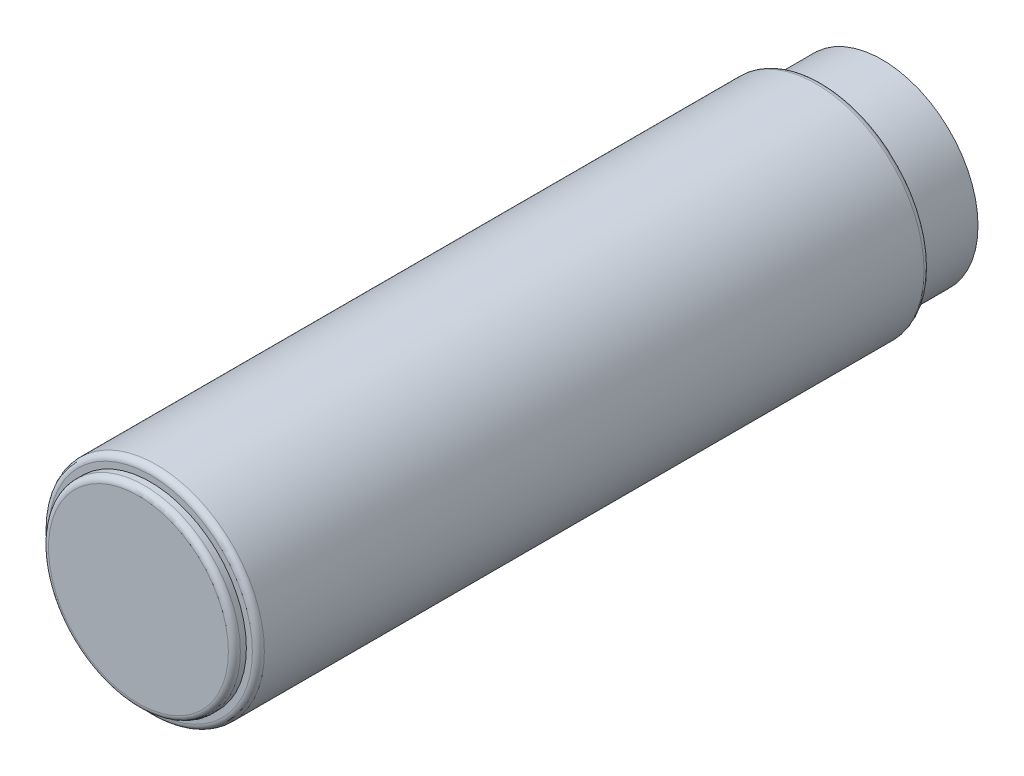
from build123d import *

# Parameters (mm, degrees)
ESQUISSE1_R        = 9
BOSS_EXTRU_1_DEPTH = 56
ESQUISSE2_R        = 8
BOSS_EXTRU_2_DEPTH = 1
ESQUISSE3_R        = 8
BOSS_EXTRU_3_DEPTH = 5
CONG_1_R           = 0.5
CONG_2_R           = 0.5
CONG_3_R           = 0.5


with BuildPart() as part:
    # Esquisse1 → Boss.-Extru.1 (new body)
    with BuildSketch(Plane.XY):
        Circle(ESQUISSE1_R)
    extrude(amount=BOSS_EXTRU_1_DEPTH)

    # Congé2
    cong_2_edges = [part.edges().sort_by_distance(p)[0] for p in [
        (-9, 0, 56),
    ]]
    fillet(cong_2_edges, radius=CONG_2_R)

    # Congé3
    cong_3_edges = [part.edges().sort_by_distance(p)[0] for p in [
        (-9, 0, 0),
    ]]
    fillet(cong_3_edges, radius=CONG_3_R)


with BuildPart() as body_2:
    # Esquisse2 → Boss.-Extru.2 (new body)
    with BuildSketch(Plane.XY.offset(56)):
        Circle(ESQUISSE2_R)
    extrude(amount=BOSS_EXTRU_2_DEPTH)

    # Congé1
    cong_1_edges = [body_2.edges().sort_by_distance(p)[0] for p in [
        (-8, 0, 57),
    ]]
    fillet(cong_1_edges, radius=CONG_1_R)


with BuildPart() as body_3:
    # Esquisse3 → Boss.-Extru.3 (new body)
    with BuildSketch(Plane(origin=(0, 0, 0), x_dir=(-1, 0, 0), z_dir=(0, 0, -1))):
        Circle(ESQUISSE3_R)
    extrude(amount=BOSS_EXTRU_3_DEPTH)


solid = Compound([part.part, body_2.part, body_3.part])
